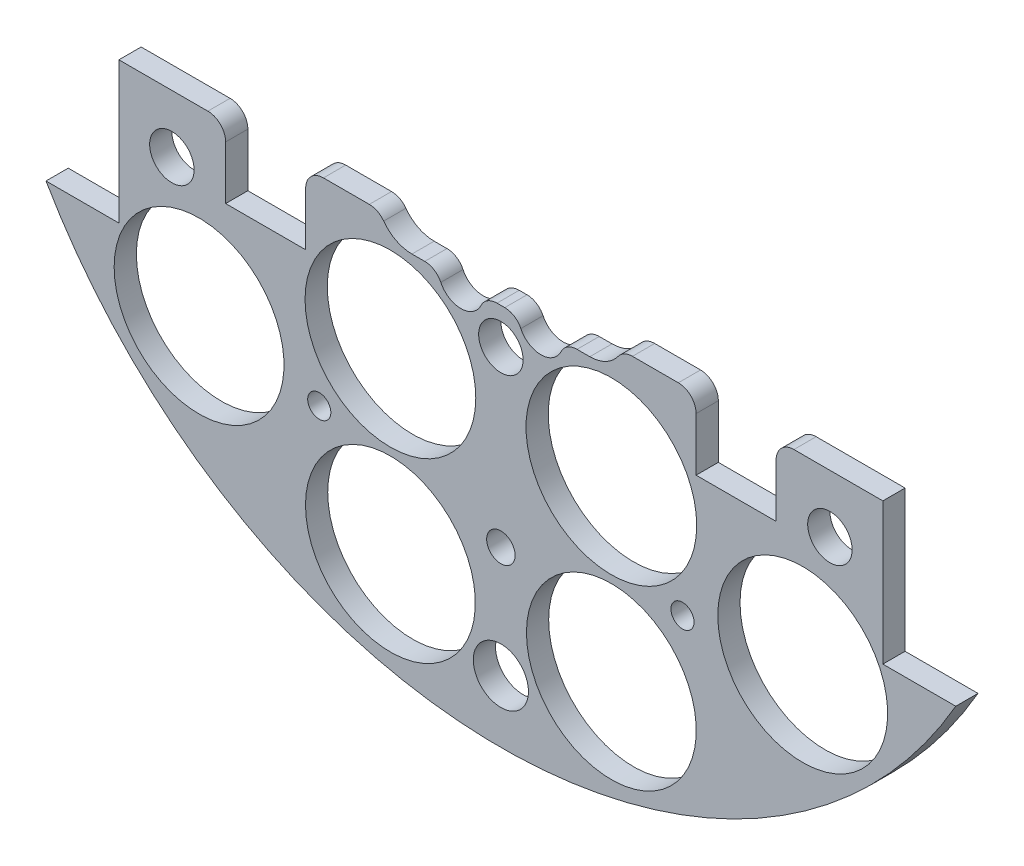
from build123d import *

# Parameters (mm, degrees)
SKETCH1_R                = 1.651
BOSS_EXTRUDE2_DEPTH      = 3.175
SKETCH2_R                = 1.143
CUT_EXTRUDE1_DEPTH       = 4.175
SKETCH3_R                = 12.1285
CUT_EXTRUDE2_DEPTH       = 4.175
SKETCH4_W                = 28.562713242
SKETCH4_H                = 11.677503754
BOSS_EXTRUDE3_DEPTH      = 3.175
SKETCH5_W                = 216.7214489
SKETCH5_H                = 130.569220634
CUT_EXTRUDE4_DEPTH       = 4.175
SKETCH11_R               = 3.937
CUT_EXTRUDE11_DEPTH      = 4.175
SKETCH12_W               = 11.43
SKETCH12_H               = 10.16
CUT_EXTRUDE12_DEPTH      = 4.175
SKETCH16_R               = 12.192
CUT_EXTRUDE16_DEPTH      = 21.59
SKETCH57_R               = 1.651
CUT_EXTRUDE57_DEPTH      = 58.674
SKETCH58_R               = 3.175
CUT_EXTRUDE58_DEPTH      = 103.378
CUT_EXTRUDE58_DEPTH_BACK = 48.768
CUT_EXTRUDE15_DEPTH      = 21.59
FILLET1_R                = 2.54
SKETCH59_R               = 2.032
CUT_EXTRUDE59_DEPTH      = 11.938


with BuildPart() as part:
    # Sketch1 → Boss-Extrude2 (new body)
    with BuildSketch(Plane.XY):
        with BuildLine():
            Line((-64.964441474, 37.338), (-54.550441474, 37.338))
            Line((-54.550441474, 37.338), (-54.550441474, -37.338))
            Line((-54.550441474, -37.338), (-64.964441474, -37.338))
            ThreePointArc((-64.964441474, -37.338), (0, -74.93), (64.964441474, -37.338))
            Line((64.964441474, -37.338), (54.550441474, -37.338))
            Line((54.550441474, -37.338), (54.550441474, 37.338))
            Line((54.550441474, 37.338), (64.964441474, 37.338))
            ThreePointArc((64.964441474, 37.338), (0, 74.93), (-64.964441474, 37.338))
        make_face()
        with Locations((-46.482, 11.049)):
            Circle(SKETCH1_R, mode=Mode.SUBTRACT)
        with Locations((-21.083270032, 10.795)):
            Circle(SKETCH1_R, mode=Mode.SUBTRACT)
        with Locations((-21.083270032, -10.795)):
            Circle(SKETCH1_R, mode=Mode.SUBTRACT)
        with Locations((-46.482, -11.049)):
            Circle(SKETCH1_R, mode=Mode.SUBTRACT)
        with Locations((46.482, -11.049)):
            Circle(SKETCH1_R, mode=Mode.SUBTRACT)
        with Locations((21.083270032, -10.795)):
            Circle(SKETCH1_R, mode=Mode.SUBTRACT)
        with Locations((21.083270032, 10.795)):
            Circle(SKETCH1_R, mode=Mode.SUBTRACT)
        with Locations((46.482, 11.049)):
            Circle(SKETCH1_R, mode=Mode.SUBTRACT)
    extrude(amount=BOSS_EXTRUDE2_DEPTH)

    # Sketch2 → Cut-Extrude1 (cut, through all)
    with BuildSketch(Plane.XY.offset(3.175)):
        with Locations((-6.731, 62.23)):
            Circle(SKETCH2_R)
        with Locations((6.731, 62.23)):
            Circle(SKETCH2_R)
    extrude(amount=-CUT_EXTRUDE1_DEPTH, mode=Mode.SUBTRACT)

    # Sketch3 → Cut-Extrude2 (cut, through all)
    with BuildSketch(Plane(origin=(0, 0, 0), x_dir=(-1, 0, 0), z_dir=(0, 0, -1))):
        with Locations((-15.777608989, -58.882838371)):
            Circle(SKETCH3_R)
        with Locations((15.777608989, -58.882838371)):
            Circle(SKETCH3_R)
        with Locations((-43.105229381, -43.105229381)):
            Circle(SKETCH3_R)
        with Locations((-43.105229381, 43.105229381)):
            Circle(SKETCH3_R)
        with Locations((43.105229381, 43.105229381)):
            Circle(SKETCH3_R)
        with Locations((43.105229381, -43.105229381)):
            Circle(SKETCH3_R)
    extrude(amount=-CUT_EXTRUDE2_DEPTH, mode=Mode.SUBTRACT)

    # Sketch4 → Boss-Extrude3 (add)
    with BuildSketch(Plane(origin=(0, 0, 0), x_dir=(-1, 0, 0), z_dir=(0, 0, -1))):
        with Locations((-1.488809975, 62.152540216)):
            Rectangle(SKETCH4_W, SKETCH4_H)
    extrude(amount=-BOSS_EXTRUDE3_DEPTH)

    # Sketch5 → Cut-Extrude4 (cut, through all)
    with BuildSketch(Plane(origin=(0, 0, 0), x_dir=(-1, 0, 0), z_dir=(0, 0, -1))):
        with Locations((23.316688373, 48.139610317)):
            Rectangle(SKETCH5_W, SKETCH5_H)
    extrude(amount=-CUT_EXTRUDE4_DEPTH, mode=Mode.SUBTRACT)

    # Sketch11 → Cut-Extrude11 (cut, through all)
    with BuildSketch(Plane(origin=(0, 0, 0), x_dir=(-1, 0, 0), z_dir=(0, 0, -1))):
        with Locations((0, -66.045)):
            Circle(SKETCH11_R)
    extrude(amount=-CUT_EXTRUDE11_DEPTH, mode=Mode.SUBTRACT)

    # Sketch12 → Cut-Extrude12 (cut, through all)
    with BuildSketch(Plane(origin=(0, 0, 0), x_dir=(-1, 0, 0), z_dir=(0, 0, -1))):
        with Locations((-33.595441474, -22.225)):
            Rectangle(SKETCH12_W, SKETCH12_H)
        with Locations((33.595441474, -22.225)):
            Rectangle(SKETCH12_W, SKETCH12_H)
    extrude(amount=-CUT_EXTRUDE12_DEPTH, mode=Mode.SUBTRACT)

    # Sketch16 → Cut-Extrude16 (cut)
    with BuildSketch(Plane(origin=(0, 0, 0), x_dir=(-1, 0, 0), z_dir=(0, 0, -1))):
        with Locations((15.777608989, -33.482838371)):
            Circle(SKETCH16_R)
        with Locations((-15.777608989, -33.482838371)):
            Circle(SKETCH16_R)
    extrude(amount=-CUT_EXTRUDE16_DEPTH, mode=Mode.SUBTRACT)

    # Sketch57 → Cut-Extrude57 (cut)
    with BuildSketch(Plane(origin=(0, 0, 0), x_dir=(-1, 0, 0), z_dir=(0, 0, -1))):
        with Locations((-25.937608989, -45.645229381)):
            Circle(SKETCH57_R)
        with Locations((25.937608989, -45.645229381)):
            Circle(SKETCH57_R)
    extrude(amount=-CUT_EXTRUDE57_DEPTH, mode=Mode.SUBTRACT)

    # Sketch58 → Cut-Extrude58 (cut, two sides)
    with BuildSketch(Plane(origin=(30.092005081, 4.08352975, 36.1315), x_dir=(-1, 0, 0), z_dir=(0, 0, -1))) as cut_extrude58_sk:
        with Locations((77.082005081, -29.48352975)):
            Circle(SKETCH58_R)
        with Locations((30.092005081, -29.48352975)):
            Circle(SKETCH58_R)
        with Locations((-16.897994919, -29.48352975)):
            Circle(SKETCH58_R)
    extrude(amount=CUT_EXTRUDE58_DEPTH, mode=Mode.SUBTRACT)
    extrude(cut_extrude58_sk.sketch, amount=-CUT_EXTRUDE58_DEPTH_BACK, mode=Mode.SUBTRACT)

    # Sketch15 → Cut-Extrude15 (cut)
    with BuildSketch(Plane(origin=(0, 0, 0), x_dir=(-1, 0, 0), z_dir=(0, 0, -1))):
        with BuildLine():
            Line((-12.7, -20.24), (-8.888991966, -20.24))
            ThreePointArc((-8.888991966, -20.24), (-5.715, -23.495), (-2.541008034, -20.24))
            Line((-2.541008034, -20.24), (2.541008034, -20.24))
            ThreePointArc((2.541008034, -20.24), (5.715, -23.495), (8.888991966, -20.24))
            Line((8.888991966, -20.24), (12.7, -20.24))
            ThreePointArc((12.7, -20.24), (16.235533906, -11.704466094), (7.7, -15.24))
            Line((7.7, -15.24), (-1.06, -15.24))
            ThreePointArc((-1.06, -15.24), (-4.010609847, -10.6792983), (-9.38, -11.501337137))
            ThreePointArc((-9.38, -11.501337137), (-17.374040774, -13.464234575), (-12.7, -20.24))
        make_face()
    extrude(amount=-CUT_EXTRUDE15_DEPTH, mode=Mode.SUBTRACT)

    # Fillet1
    fillet1_edges = [part.edges().sort_by_distance(p)[0] for p in [
        (39.310441474, -17.145, 1.5875),
        (27.880441474, -17.145, 1.5875),
        (-27.880441474, -17.145, 1.5875),
        (-39.310441474, -17.145, 1.5875),
        (-17.322875188, -17.145, 1.5875),
        (17.322875188, -17.145, 1.5875),
        (-8.888991966, -20.24, 1.5875),
        (-2.541008034, -20.24, 1.5875),
        (2.541008034, -20.24, 1.5875),
        (8.888991966, -20.24, 1.5875),
    ]]
    fillet(fillet1_edges, radius=FILLET1_R)

    # Sketch59 → Cut-Extrude59 (cut)
    with BuildSketch(Plane(origin=(0, 0, 0), x_dir=(-1, 0, 0), z_dir=(0, 0, -1))):
        with Locations((0, -50.165)):
            Circle(SKETCH59_R)
    extrude(amount=-CUT_EXTRUDE59_DEPTH, mode=Mode.SUBTRACT)


solid = part.part
